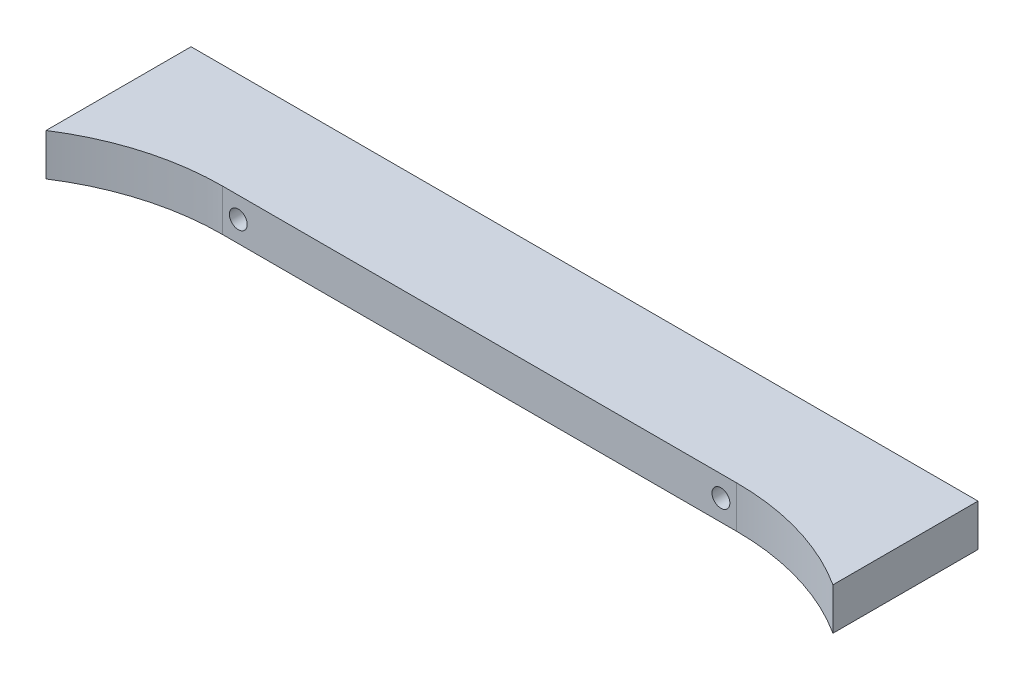
from build123d import *

# Parameters (mm, degrees)
EXTRUDE_1_DEPTH              = 8
HOLE_WIZARD_M3_1_D           = 3.4
HOLE_WIZARD_M3_1_CBORE_D     = 6.5
HOLE_WIZARD_M3_1_CBORE_DEPTH = 16
SKETCH_4_R                   = 2.6
CUT_EXTRUDE_1_DEPTH          = 10


with BuildPart() as part:
    # 草图1 → 凸台-拉伸1 (new body)
    with BuildSketch(Plane(origin=(0, 0, 0), x_dir=(1, 0, 0), z_dir=(0, 1, 0))):
        Polygon((-75, -10), (-49, -10), (49, -10), (75, -10), (75, 10), (-75, 10), align=None)
        with BuildLine():
            ThreePointArc((-75, -17.651517996), (-62.551252042, -11.952594339), (-49, -10))
            Line((-49, -10), (-75, -10))
            Line((-75, -10), (-75, -17.651517996))
        make_face()
        with BuildLine():
            Line((75, -10), (49, -10))
            ThreePointArc((49, -10), (62.551252042, -11.952594339), (75, -17.651517996))
            Line((75, -17.651517996), (75, -10))
        make_face()
    extrude(amount=EXTRUDE_1_DEPTH)

    # M3 六角凹头螺钉的柱形沉头孔1 (through all)
    with Locations(Plane(origin=(46, 4, -10), x_dir=(-1, 0, 0), z_dir=(0, 0, -1))):
        with Locations((0, 0), (92, 0)):
            CounterBoreHole(HOLE_WIZARD_M3_1_D / 2, HOLE_WIZARD_M3_1_CBORE_D / 2, HOLE_WIZARD_M3_1_CBORE_DEPTH)

    # 草图4 → 切除-拉伸1 (cut)
    with BuildSketch(Plane(origin=(0, 0, -10), x_dir=(-1, 0, 0), z_dir=(0, 0, -1))):
        with Locations((-55, 4)):
            Circle(SKETCH_4_R)
        with Locations((55, 4)):
            Circle(SKETCH_4_R)
    extrude(amount=-CUT_EXTRUDE_1_DEPTH, mode=Mode.SUBTRACT)


solid = part.part
